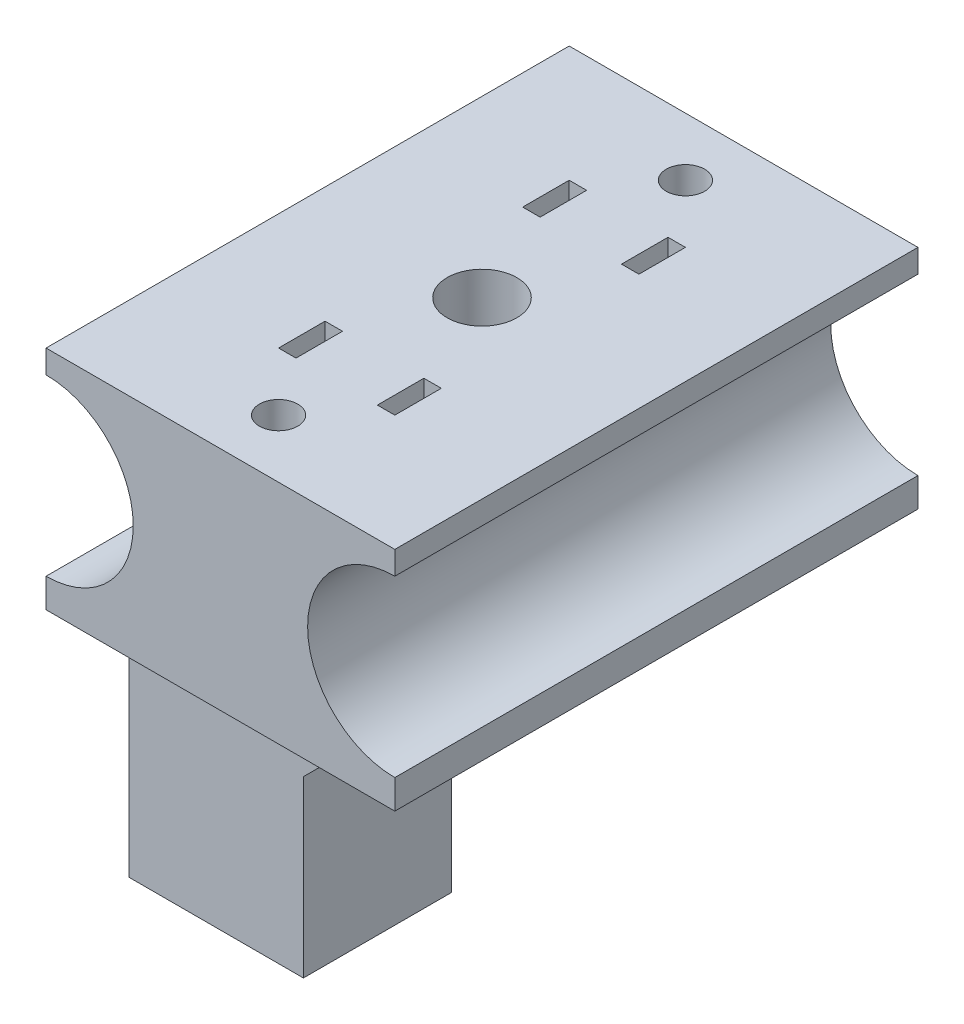
from build123d import *

# Parameters (mm, degrees)
BOSS_EXTRUDE1_DEPTH       = 22.5
M4X0_7_TAPPED_HOLE2_D     = 3.3
BOSS_EXTRUDE3_DEPTH       = 6.3625
M4X0_7_TAPPED_HOLE1_D     = 3.3
M4X0_7_TAPPED_HOLE1_DEPTH = 10
M4X0_7_TAPPED_HOLE1_TIP   = 0.991420021
CUT_EXTRUDE2_DEPTH        = 85
SKETCH2_R                 = 3
CUT_EXTRUDE1_DEPTH        = 50
CUT_EXTRUDE3_START        = -10
CUT_EXTRUDE3_DEPTH        = 4


with BuildPart() as part:
    # Sketch1 → Boss-Extrude1 (new body, symmetric)
    with BuildSketch(Plane.XY):
        with BuildLine():
            Line((-15, 7.5), (-15, 9.5))
            Line((-15, 9.5), (15, 9.5))
            Line((15, 9.5), (15, 7.5))
            ThreePointArc((15, 7.5), (7.5, 0), (15, -7.5))
            Line((15, -7.5), (15, -10))
            Line((15, -10), (-15, -10))
            Line((-15, -10), (-15, -7.5))
            ThreePointArc((-15, -7.5), (-7.5, 0), (-15, 7.5))
        make_face()
    extrude(amount=BOSS_EXTRUDE1_DEPTH, both=True)

    # M4x0.7 Tapped Hole2 (through all)
    with Locations(Plane(origin=(0, -10, 0), x_dir=(-1, 0, 0), z_dir=(0, -1, 0))):
        with Locations((0, -17.5), (0, 17.5)):
            Hole(M4X0_7_TAPPED_HOLE2_D / 2)

    # Sketch7 → Boss-Extrude3 (add, symmetric)
    with BuildSketch(Plane.XY):
        Polygon((-15, -7.5), (-24, -7.5), (-24, -42.5), (-9, -42.5), (-9, -27.5), (8.5, -10), (-15, -10), align=None)
    extrude(amount=BOSS_EXTRUDE3_DEPTH, both=True)

    # M4x0.7 Tapped Hole1
    with Locations(Plane(origin=(-24, 0, 0), x_dir=(0, 0, -1), z_dir=(-1, 0, 0))):
        with Locations((0, 37.5), (0, 22.5)):
            Hole(M4X0_7_TAPPED_HOLE1_D / 2, depth=M4X0_7_TAPPED_HOLE1_DEPTH)
            with Locations((0, 0, -(M4X0_7_TAPPED_HOLE1_DEPTH + M4X0_7_TAPPED_HOLE1_TIP / 2))):  # 118° drill point
                Cone(0, M4X0_7_TAPPED_HOLE1_D / 2, M4X0_7_TAPPED_HOLE1_TIP, mode=Mode.SUBTRACT)

    # Sketch10 → Cut-Extrude2 (cut)
    with BuildSketch(Plane(origin=(0, 0, -6.3625), x_dir=(-1, 0, 0), z_dir=(0, 0, -1))):
        Polygon((15, -10), (24, -19), (24, -7.5), (15, -7.5), align=None)
    extrude(amount=-CUT_EXTRUDE2_DEPTH, mode=Mode.SUBTRACT)

    # Sketch2 → Cut-Extrude1 (cut)
    with BuildSketch(Plane(origin=(0, 9.5, 0), x_dir=(1, 0, 0), z_dir=(0, 1, 0))):
        Circle(SKETCH2_R)
    extrude(amount=-CUT_EXTRUDE1_DEPTH, mode=Mode.SUBTRACT)

    # Sketch11 → Cut-Extrude3 (cut)
    with BuildSketch(Plane(origin=(0, 0, -22.5), x_dir=(-1, 0, 0), z_dir=(0, 0, -1)).offset(CUT_EXTRUDE3_START)):
        with BuildLine():
            Line((-5, 9.5), (-5, 0))
            ThreePointArc((-5, 0), (-7.928932188, -7.071067812), (-15, -10))
            Line((-15, -10), (-3.5, -10))
            Line((-3.5, -10), (-3.5, 9.5))
            Line((-3.5, 9.5), (-5, 9.5))
        make_face()
        with BuildLine():
            Line((3.5, 9.5), (5, 9.5))
            Line((5, 9.5), (5, 0))
            ThreePointArc((5, 0), (7.928932188, -7.071067812), (15, -10))
            Line((15, -10), (3.5, -10))
            Line((3.5, -10), (3.5, 9.5))
        make_face()
    cut_extrude3 = extrude(amount=-CUT_EXTRUDE3_DEPTH, mode=Mode.SUBTRACT)

    # Mirror1: Cut-Extrude3 across plane
    add(cut_extrude3.mirror(Plane.XY), mode=Mode.SUBTRACT)


solid = part.part
